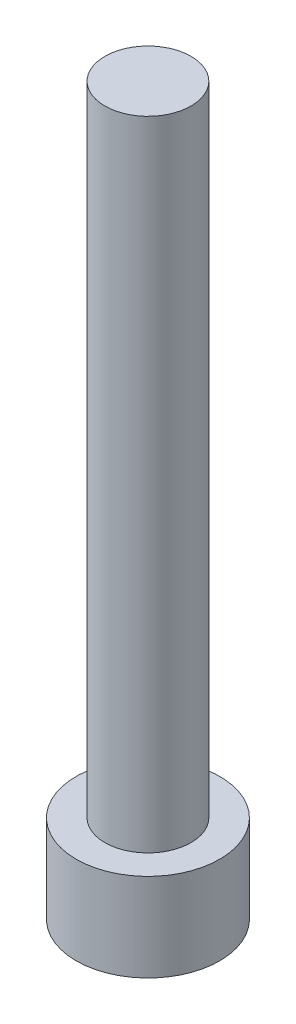
from build123d import *

# Parameters (mm, degrees)
SKETCH1_R           = 2.8575
BOSS_EXTRUDE1_DEPTH = 3.5052
CUT_EXTRUDE1_DEPTH  = 1.9558
SKETCH3_R           = 1.7145
BOSS_EXTRUDE2_DEPTH = 25.4


with BuildPart() as part:
    # Sketch1 → Boss-Extrude1 (new body)
    with BuildSketch(Plane(origin=(0, 0, 0), x_dir=(1, 0, 0), z_dir=(0, 1, 0))):
        Circle(SKETCH1_R)
    extrude(amount=BOSS_EXTRUDE1_DEPTH)

    # Sketch2 → Cut-Extrude1 (cut)
    with BuildSketch(Plane.XZ):
        Polygon((1.603951217, 0), (0.801975608, 1.3890625), (-0.801975608, 1.3890625), (-1.603951217, 0), (-0.801975608, -1.3890625), (0.801975608, -1.3890625), align=None)
    extrude(amount=-CUT_EXTRUDE1_DEPTH, mode=Mode.SUBTRACT)

    # Sketch3 → Boss-Extrude2 (add)
    with BuildSketch(Plane(origin=(0, 3.5052, 0), x_dir=(1, 0, 0), z_dir=(0, 1, 0))):
        Circle(SKETCH3_R)
    extrude(amount=BOSS_EXTRUDE2_DEPTH)


solid = part.part
